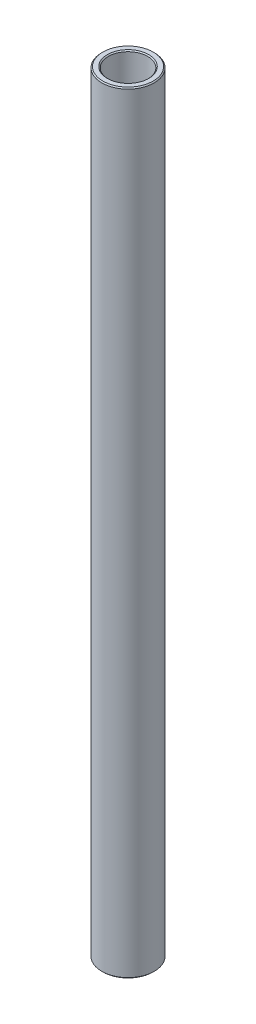
from build123d import *

# Parameters (mm, degrees)
SKETCH1_W     = 1.5875
SKETCH1_H     = 186.902515209
CHAMFER1_SIZE = 0.254


with BuildPart() as part:
    # Sketch1 → Revolve1 (revolve)
    with BuildSketch(Plane.XY):
        with Locations((5.55625, 219.815900685)):
            Rectangle(SKETCH1_W, SKETCH1_H)
    revolve(axis=Axis((0, 116.839643081, 0), (0, 1, 0)))

    # Chamfer1
    chamfer1_edges = [part.edges().sort_by_distance(p)[0] for p in [
        (-6.35, 126.364643081, 0),
        (-6.350000001, 313.26715829, 0),
        (-4.762500001, 313.26715829, 0),
        (-4.7625, 126.364643081, 0),
    ]]
    chamfer(chamfer1_edges, length=CHAMFER1_SIZE)


solid = part.part
